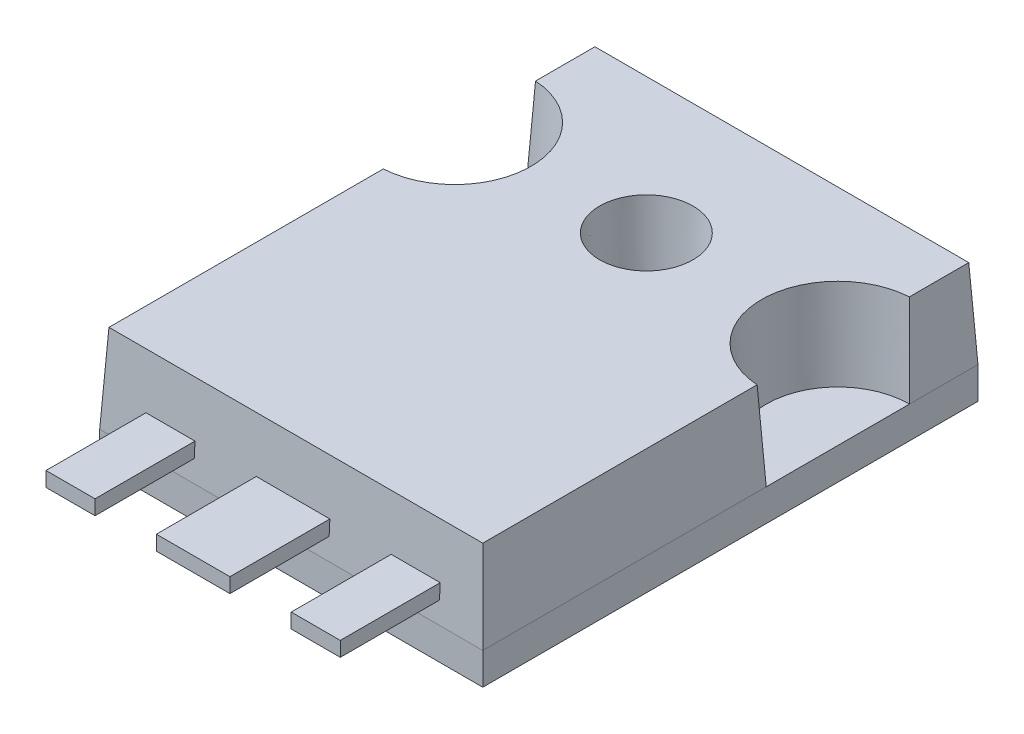
from build123d import *

# Parameters (mm, degrees)
SKETCH1_W                = 15.621
SKETCH1_H                = 20.193
SKETCH1_R                = 1.7145
BOSS_EXTRUDE1_DEPTH      = 1.3
SKETCH2_R                = 1.7145
BOSS_EXTRUDE2_DEPTH      = 3.6
BOSS_EXTRUDE2_DRAFT      = 3
SKETCH3_W                = 2
SKETCH3_H                = 2.155291512
SKETCH3_H_2              = 4
SKETCH3_W_2              = 1.5
SKETCH3_H_3              = 2.998822354
BOSS_EXTRUDE3_DEPTH      = 0.3
BOSS_EXTRUDE3_DEPTH_BACK = 0.3


with BuildPart() as part:
    # Sketch1 → Boss-Extrude1 (new body)
    with BuildSketch(Plane(origin=(0, 0, 0), x_dir=(1, 0, 0), z_dir=(0, 1, 0))):
        with Locations((7.8105, 10.0965)):
            Rectangle(SKETCH1_W, SKETCH1_H)
        with Locations((7.8105, 14.4785)):
            Circle(SKETCH1_R, mode=Mode.SUBTRACT)
    extrude(amount=BOSS_EXTRUDE1_DEPTH)


with BuildPart() as boss_extrude2_tool:
    # Sketch2 → Boss-Extrude2 (with draft: the straight prism first)
    with BuildSketch(Plane(origin=(0, 1.3, 0), x_dir=(1, 0, 0), z_dir=(0, 1, 0))):
        with BuildLine():
            Line((15.621, 20.193), (0, 20.193))
            Line((0, 20.193), (0, 17.3995))
            ThreePointArc((0, 17.3995), (2.065458908, 16.543958908), (2.921, 14.4785))
            ThreePointArc((2.921, 14.4785), (2.065458908, 12.413041092), (0, 11.5575))
            Line((0, 11.5575), (0, 0))
            Line((0, 0), (15.621, 0))
            Line((15.621, 0), (15.621, 11.5575))
            ThreePointArc((15.621, 11.5575), (12.7, 14.4785), (15.621, 17.3995))
            Line((15.621, 17.3995), (15.621, 20.193))
        make_face()
        with Locations((7.8105, 14.4785)):
            Circle(SKETCH2_R, mode=Mode.SUBTRACT)
    extrude(amount=BOSS_EXTRUDE2_DEPTH)
    # Boss-Extrude2: the draft: its side faces are tilted about the plane it starts from
    boss_extrude2_sides = [boss_extrude2_tool.faces().sort_by_distance(p)[0] for p in [
        (15.621, 3.1, -18.79625),
        (6.096, 3.1, -14.4785),
        (15.621, 3.1, -5.77875),
        (7.8105, 3.1, 0),
        (0, 3.1, -5.77875),
        (2.921, 3.1, -14.4785),
        (0, 3.1, -18.79625),
        (7.8105, 3.1, -20.193),
        (12.7, 3.1, -14.4785),
    ]]
    draft(boss_extrude2_sides, Plane(origin=(0, 1.3, 0), x_dir=(1, 0, 0), z_dir=(0, 1, 0)), BOSS_EXTRUDE2_DRAFT)


with BuildPart() as part_1:
    add(part.part)

    # Boss-Extrude2: add boss_extrude2_tool
    add(boss_extrude2_tool.part)

    # Sketch3 → Boss-Extrude3 (add, two sides)
    with BuildSketch(Plane(origin=(0, 2.45, 0), x_dir=(1, 0, 0), z_dir=(0, 1, 0))) as boss_extrude3_sk:
        with Locations((2.8105, 1.077645756)):
            Rectangle(SKETCH3_W, SKETCH3_H)
        with Locations((2.8105, -2)):
            Rectangle(SKETCH3_W, SKETCH3_H_2)
        with Locations((12.8105, 1.077645756)):
            Rectangle(SKETCH3_W, SKETCH3_H)
        with Locations((12.8105, -2)):
            Rectangle(SKETCH3_W, SKETCH3_H_2)
        with Locations((7.0605, 1.499411177)):
            Rectangle(SKETCH3_W_2, SKETCH3_H_3)
        Polygon((7.8105, 0), (6.3105, 0), (6.3105, -4), (9.3105, -4), (9.3105, 0), align=None)
        with Locations((8.5605, 1.499411177)):
            Rectangle(SKETCH3_W_2, SKETCH3_H_3)
    extrude(amount=BOSS_EXTRUDE3_DEPTH)
    extrude(boss_extrude3_sk.sketch, amount=-BOSS_EXTRUDE3_DEPTH_BACK)


solid = part_1.part
